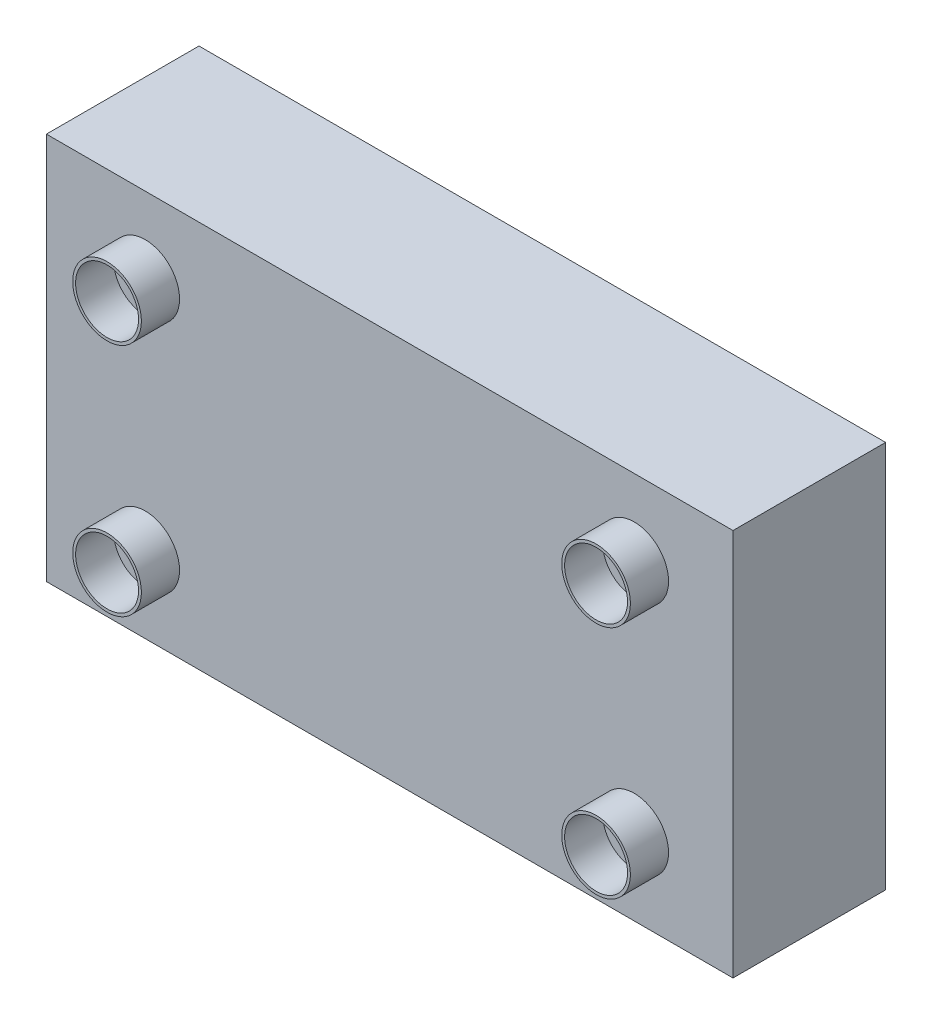
from build123d import *

# Parameters (mm, degrees)
SKETCH1_W           = 180
SKETCH1_H           = 101.6
BOSS_EXTRUDE1_DEPTH = 40
SKETCH3_W           = 160
SKETCH3_H           = 81.6
CUT_EXTRUDE3_DEPTH  = 5
SKETCH4_R           = 9
BOSS_EXTRUDE2_DEPTH = 10
SKETCH5_R           = 8.25
CUT_EXTRUDE4_DEPTH  = 10


with BuildPart() as part:
    # Sketch1 → Boss-Extrude1 (new body)
    with BuildSketch(Plane.XY):
        Rectangle(SKETCH1_W, SKETCH1_H)
    extrude(amount=BOSS_EXTRUDE1_DEPTH)

    # Sketch3 → Cut-Extrude3 (cut)
    with BuildSketch(Plane(origin=(0, 0, 0), x_dir=(-1, 0, 0), z_dir=(0, 0, -1))):
        Rectangle(SKETCH3_W, SKETCH3_H)
    extrude(amount=-CUT_EXTRUDE3_DEPTH, mode=Mode.SUBTRACT)

    # Sketch4 → Boss-Extrude2 (add)
    with BuildSketch(Plane.XY.offset(40)):
        with Locations((-64.1, 30.8)):
            Circle(SKETCH4_R)
        with Locations((-64.1, -30.8)):
            Circle(SKETCH4_R)
        with Locations((64.1, 30.8)):
            Circle(SKETCH4_R)
        with Locations((64.1, -30.8)):
            Circle(SKETCH4_R)
    extrude(amount=BOSS_EXTRUDE2_DEPTH)

    # Sketch5 → Cut-Extrude4 (cut)
    with BuildSketch(Plane.XY.offset(50)):
        with Locations((-64.1, 30.8)):
            Circle(SKETCH5_R)
        with Locations((64.1, 30.8)):
            Circle(SKETCH5_R)
        with Locations((64.1, -30.8)):
            Circle(SKETCH5_R)
        with Locations((-64.1, -30.8)):
            Circle(SKETCH5_R)
    extrude(amount=-CUT_EXTRUDE4_DEPTH, mode=Mode.SUBTRACT)


solid = part.part
